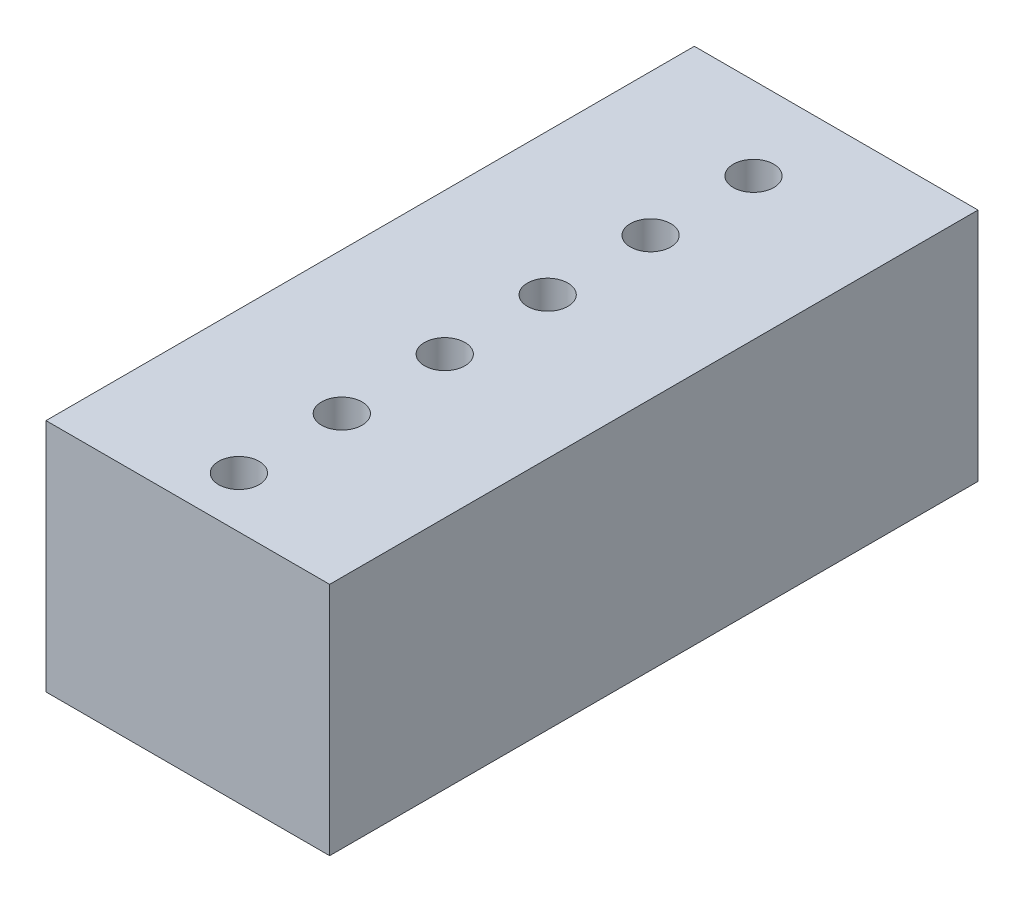
from build123d import *

# Parameters (mm, degrees)
SKETCH1_W           = 7
SKETCH1_H           = 16
BOSS_EXTRUDE1_DEPTH = 2.9
SKETCH2_R           = 0.5
CUT_EXTRUDE1_DEPTH  = 6.8
LPATTERN1_COUNT     = 12
LPATTERN1_PITCH     = 2.54


with BuildPart() as part:
    # Sketch1 → Boss-Extrude1 (new body, symmetric)
    with BuildSketch(Plane(origin=(0, 0, 0), x_dir=(1, 0, 0), z_dir=(0, 1, 0))):
        Rectangle(SKETCH1_W, SKETCH1_H)
    extrude(amount=BOSS_EXTRUDE1_DEPTH, both=True)

    # Sketch2 → Cut-Extrude1 (cut, through all)
    with BuildSketch(Plane(origin=(0, 2.9, 0), x_dir=(1, 0, 0), z_dir=(0, 1, 0))):
        with Locations((0, 5.96)):
            Circle(SKETCH2_R)
    cut_extrude1 = extrude(amount=-CUT_EXTRUDE1_DEPTH, mode=Mode.SUBTRACT)

    # LPattern1: Cut-Extrude1 ×12
    with Locations(*[(0, 0, i * LPATTERN1_PITCH) for i in range(1, LPATTERN1_COUNT)]):
        add(cut_extrude1, mode=Mode.SUBTRACT)


solid = part.part
